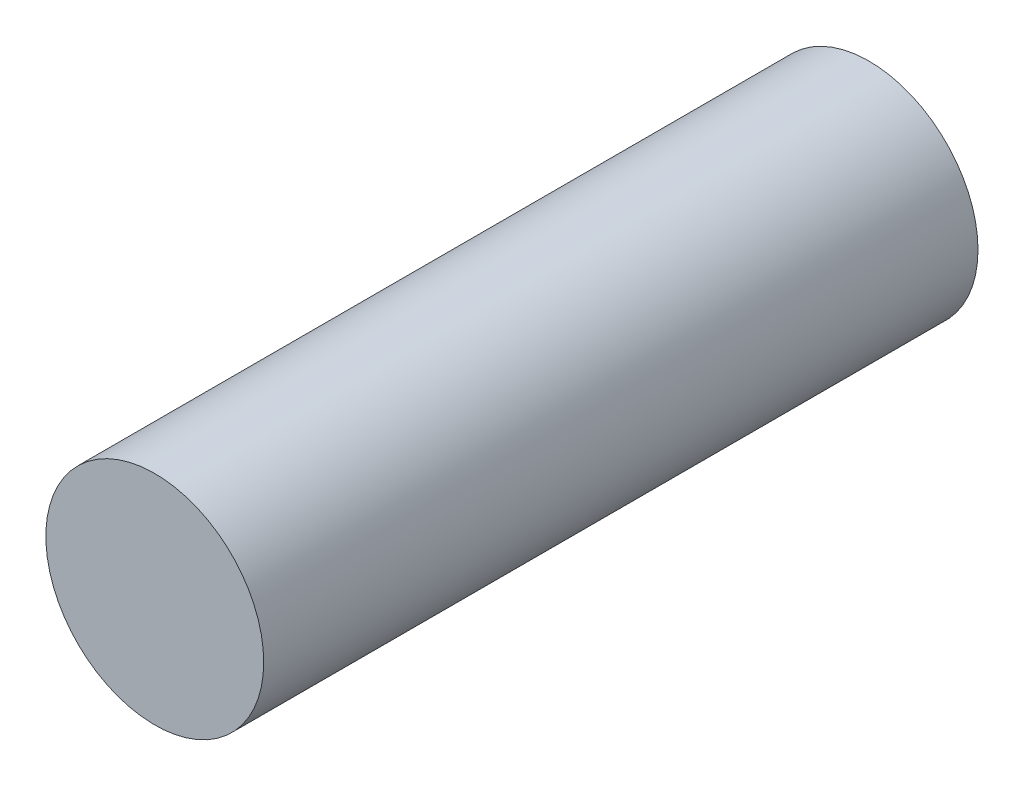
from build123d import *

# Parameters (mm, degrees)
SKETCH1_R                = 3.05
BOSS_EXTRUDE1_DEPTH      = 3
BOSS_EXTRUDE1_DEPTH_BACK = 17


with BuildPart() as part:
    # Sketch1 → Boss-Extrude1 (new body, two sides)
    with BuildSketch(Plane.XY) as boss_extrude1_sk:
        with Locations((8.5, 4)):
            Circle(SKETCH1_R)
    extrude(amount=BOSS_EXTRUDE1_DEPTH)
    extrude(boss_extrude1_sk.sketch, amount=-BOSS_EXTRUDE1_DEPTH_BACK)


solid = part.part
